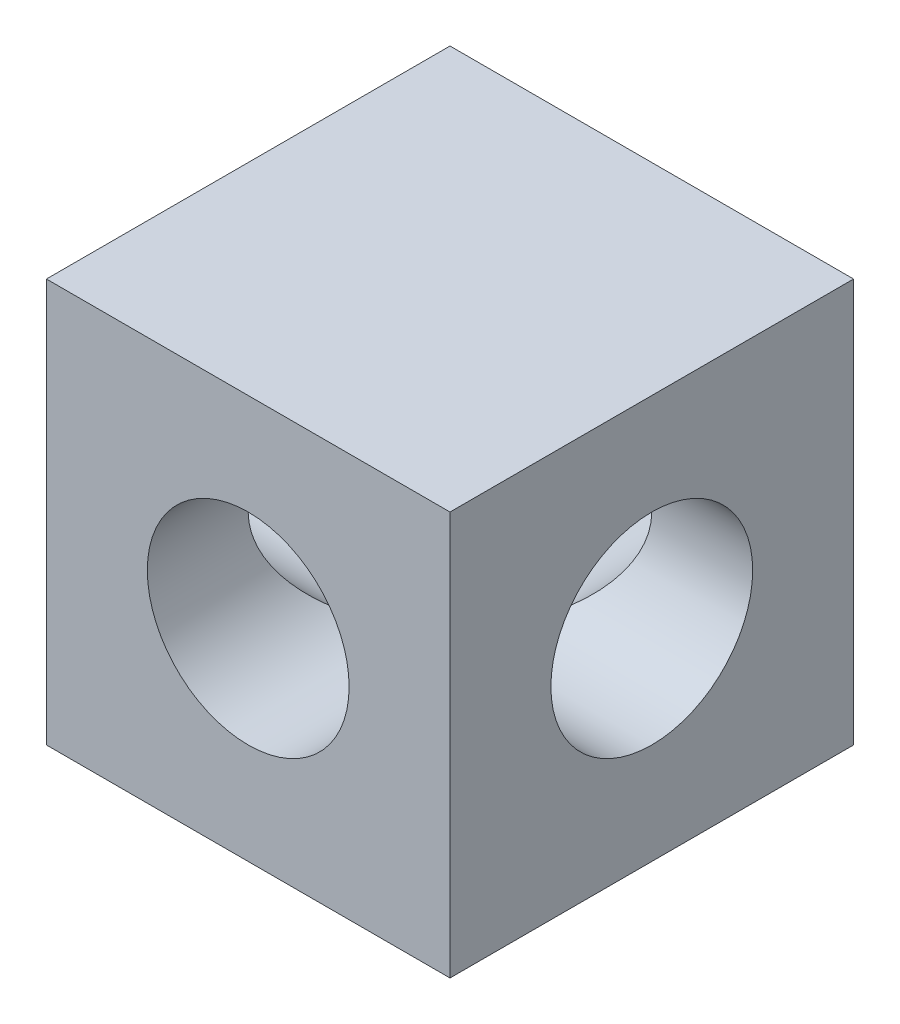
from build123d import *

# Parameters (mm, degrees)
SKETCH1_W          = 19.05
SKETCH1_H          = 19.05
SKETCH1_R          = 4.7625
BASE_EXTRUDE_DEPTH = 9.525
SKETCH3_R          = 4.7625
CUT_EXTRUDE1_DEPTH = 24.3313898


with BuildPart() as part:
    # Sketch1 → Base-Extrude (new, symmetric)
    with BuildSketch(Plane.XY):
        Rectangle(SKETCH1_W, SKETCH1_H)
        with Locations(Location((0, 0, 0), (0, 0, 180))):
            Circle(SKETCH1_R, mode=Mode.SUBTRACT)
    extrude(amount=BASE_EXTRUDE_DEPTH, both=True)

    # Sketch3 → Cut-Extrude1 (cut, through all)
    with BuildSketch(Plane(origin=(9.525, 0, 0), x_dir=(0, 0, -1), z_dir=(1, 0, 0))):
        Circle(SKETCH3_R)
    extrude(amount=-CUT_EXTRUDE1_DEPTH, mode=Mode.SUBTRACT)


solid = part.part
